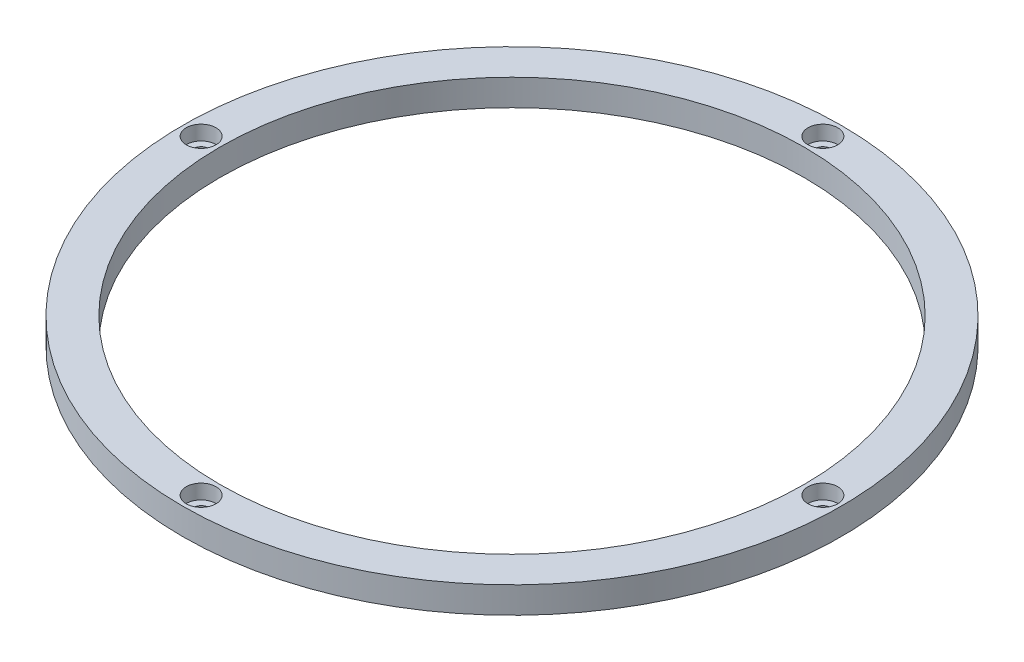
from build123d import *

# Parameters (mm, degrees)
SKETCH1_R                                      = 79.248
SKETCH1_R_2                                    = 70.2564
EXTRUDE2_DEPTH                                 = 6.35
CBORE_FOR_6_SOCKET_HEAD_CAP_SCREW1_D           = 3.7973
CBORE_FOR_6_SOCKET_HEAD_CAP_SCREW1_CBORE_D     = 7.14502
CBORE_FOR_6_SOCKET_HEAD_CAP_SCREW1_CBORE_DEPTH = 3.5052


with BuildPart() as part:
    # Sketch1 → Extrude2 (new body)
    with BuildSketch(Plane(origin=(0, 0, 0), x_dir=(1, 0, 0), z_dir=(0, 1, 0))):
        Circle(SKETCH1_R)
        Circle(SKETCH1_R_2, mode=Mode.SUBTRACT)
    extrude(amount=EXTRUDE2_DEPTH)

    # CBORE for _6 Socket Head Cap Screw1 (through all)
    with Locations(Plane(origin=(0, 6.35, -74.7522), x_dir=(0, 0, 1), z_dir=(0, 1, 0))):
        with Locations((0, 0), (149.5044, 0), (74.7522, 74.7522), (74.7522, -74.7522)):
            CounterBoreHole(CBORE_FOR_6_SOCKET_HEAD_CAP_SCREW1_D / 2, CBORE_FOR_6_SOCKET_HEAD_CAP_SCREW1_CBORE_D / 2, CBORE_FOR_6_SOCKET_HEAD_CAP_SCREW1_CBORE_DEPTH)


solid = part.part
